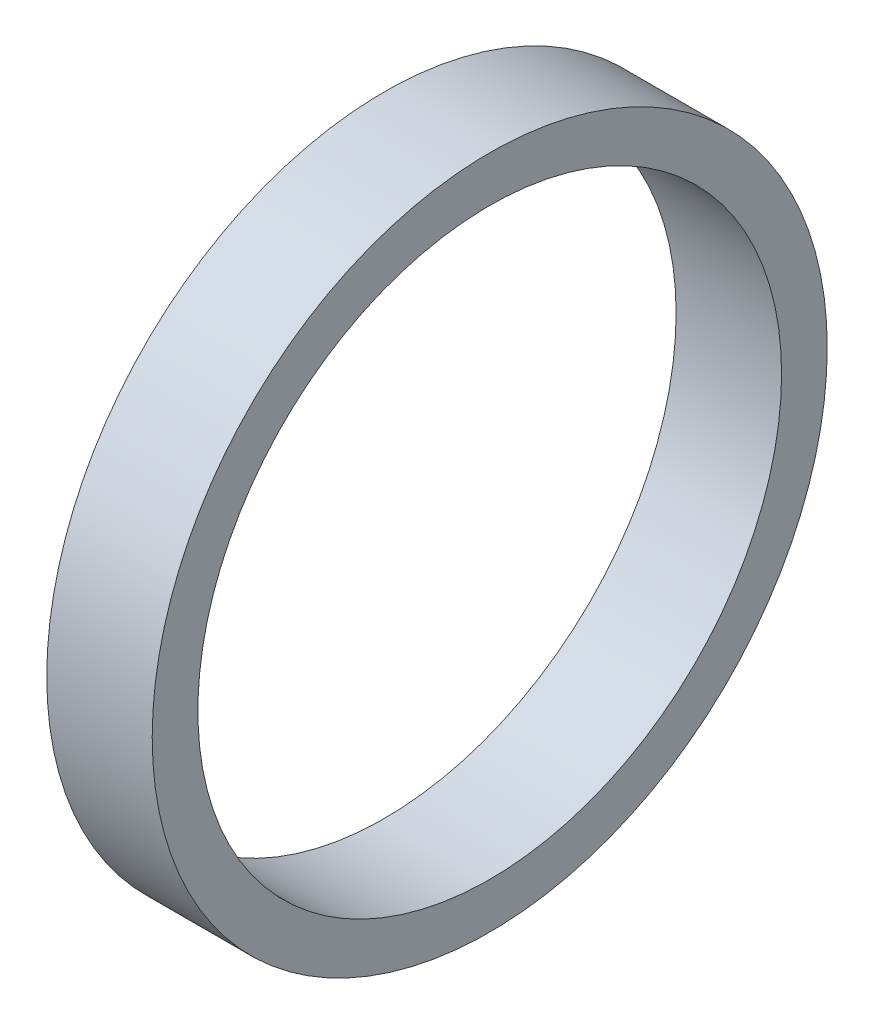
from build123d import *

# Parameters (mm, degrees)
SKETCH1_R           = 20.325022
SKETCH1_R_2         = 17.575022
BOSS_EXTRUDE1_DEPTH = 6.35


with BuildPart() as part:
    # Sketch1 → Boss-Extrude1 (new body)
    with BuildSketch(Plane(origin=(0, 0, 0), x_dir=(0, 0, -1), z_dir=(1, 0, 0))):
        Circle(SKETCH1_R)
        Circle(SKETCH1_R_2, mode=Mode.SUBTRACT)
    extrude(amount=BOSS_EXTRUDE1_DEPTH)


solid = part.part
